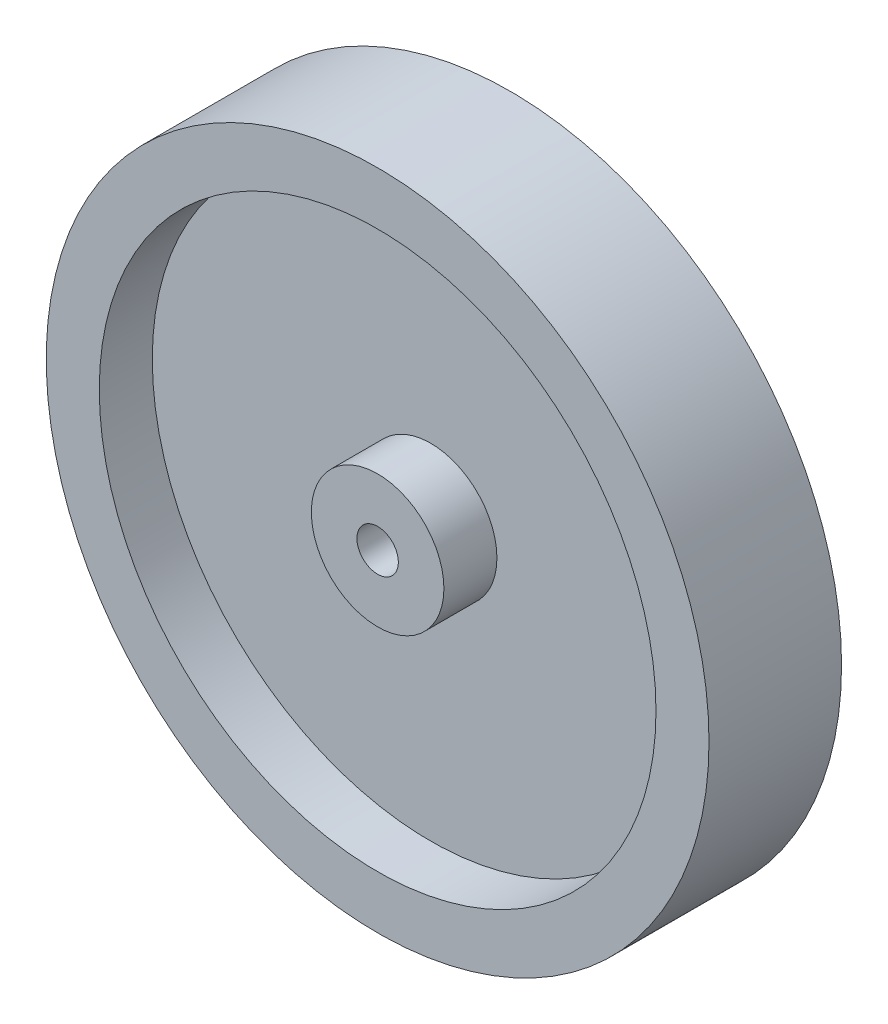
from build123d import *

# Parameters (mm, degrees)
SKETCH1_R           = 63.5
SKETCH1_R_2         = 3.96875
BOSS_EXTRUDE1_DEPTH = 12.7
SKETCH2_R           = 53.34
SKETCH2_R_2         = 12.7
CUT_EXTRUDE1_DEPTH  = 10.16


with BuildPart() as part:
    # Sketch1 → Boss-Extrude1 (new body, symmetric)
    with BuildSketch(Plane.XY):
        Circle(SKETCH1_R)
        Circle(SKETCH1_R_2, mode=Mode.SUBTRACT)
    extrude(amount=BOSS_EXTRUDE1_DEPTH, both=True)

    # Sketch2 → Cut-Extrude1 (cut)
    with BuildSketch(Plane.XY.offset(12.7)):
        Circle(SKETCH2_R)
        Circle(SKETCH2_R_2, mode=Mode.SUBTRACT)
    cut_extrude1 = extrude(amount=-CUT_EXTRUDE1_DEPTH, mode=Mode.SUBTRACT)

    # Mirror1: Cut-Extrude1 across plane
    add(cut_extrude1.mirror(Plane.XY), mode=Mode.SUBTRACT)


solid = part.part
